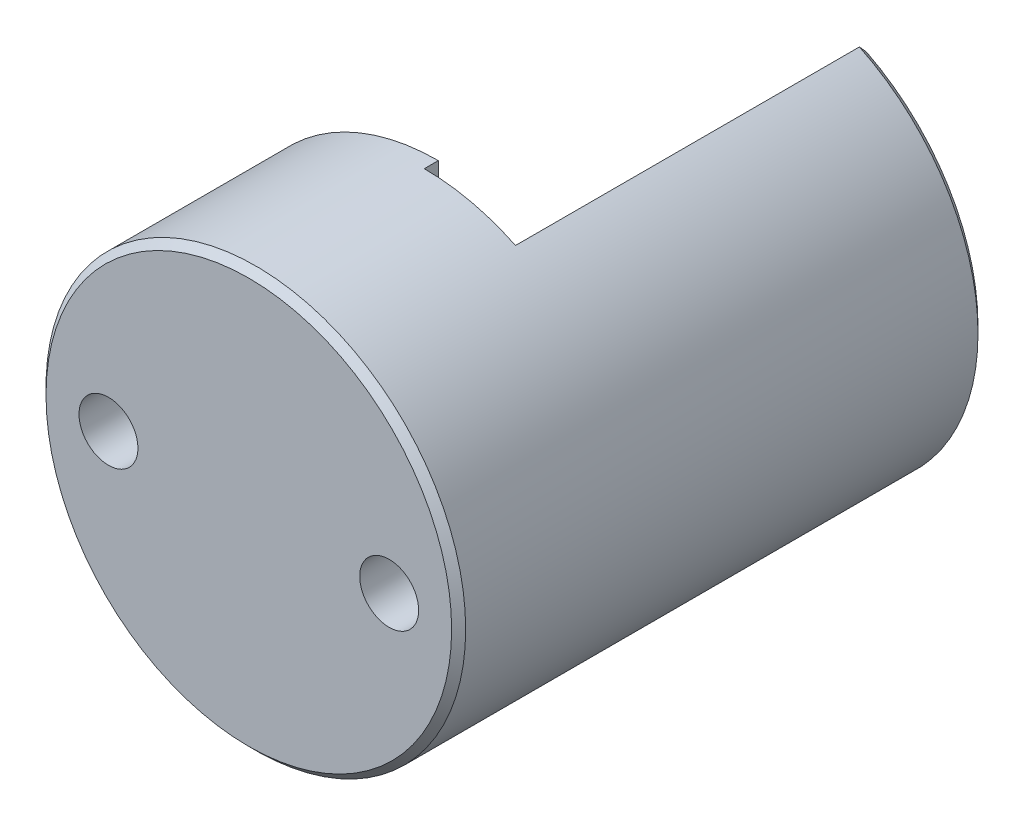
from build123d import *

# Parameters (mm, degrees)
SKETCH1_R           = 14.949572774
SKETCH1_R_2         = 2.099903903
BOSS_EXTRUDE1_DEPTH = 7.5
SKETCH2_R           = 14.949572774
BOSS_EXTRUDE2_DEPTH = 5
BOSS_EXTRUDE3_DEPTH = 1
BOSS_EXTRUDE4_DEPTH = 25
SKETCH5_R           = 2.099903903
CUT_EXTRUDE1_DEPTH  = 7
CHAMFER2_SIZE       = 0.5
CHAMFER3_SIZE       = 0.5


with BuildPart() as part:
    # Sketch1 → Boss-Extrude1 (new body)
    with BuildSketch(Plane.XY):
        Circle(SKETCH1_R)
        with Locations((9.999999776, -1e-09)):
            Circle(SKETCH1_R_2, mode=Mode.SUBTRACT)
        with Locations((-9.999999776, 1e-09)):
            Circle(SKETCH1_R_2, mode=Mode.SUBTRACT)
    extrude(amount=-BOSS_EXTRUDE1_DEPTH)

    # Sketch2 → Boss-Extrude2 (add)
    with BuildSketch(Plane(origin=(0, 0, -7.5), x_dir=(-1, 0, 0), z_dir=(0, 0, -1))):
        Circle(SKETCH2_R)
    extrude(amount=BOSS_EXTRUDE2_DEPTH)

    # Sketch3 → Boss-Extrude3 (add)
    with BuildSketch(Plane(origin=(0, 0, -12.5), x_dir=(-1, 0, 0), z_dir=(0, 0, -1))):
        with BuildLine():
            Line((-1e-09, 14.949572774), (-1e-09, -14.949572774))
            ThreePointArc((-1e-09, -14.949572774), (14.949572774, 0), (-1e-09, 14.949572774))
        make_face()
    extrude(amount=BOSS_EXTRUDE3_DEPTH)

    # Sketch4 → Boss-Extrude4 (add)
    with BuildSketch(Plane(origin=(0, 0, -12.5), x_dir=(-1, 0, 0), z_dir=(0, 0, -1))):
        with BuildLine():
            Line((-6.499816063, 13.462619257), (-6.499816063, -13.462619257))
            ThreePointArc((-6.499816063, -13.462619257), (-14.949572774, 0), (-6.499816063, 13.462619257))
        make_face()
    extrude(amount=BOSS_EXTRUDE4_DEPTH)

    # Sketch5 → Cut-Extrude1 (cut)
    with BuildSketch(Plane(origin=(0, 0, -37.5), x_dir=(-1, 0, 0), z_dir=(0, 0, -1))):
        with Locations((-9.999999776, -1e-09)):
            Circle(SKETCH5_R)
    extrude(amount=-CUT_EXTRUDE1_DEPTH, mode=Mode.SUBTRACT)

    # Chamfer2
    chamfer2_edges = [part.edges().sort_by_distance(p)[0] for p in [
        (14.949572774, 0, -37.5),
    ]]
    chamfer(chamfer2_edges, length=CHAMFER2_SIZE)

    # Chamfer3
    chamfer3_edges = [part.edges().sort_by_distance(p)[0] for p in [
        (-14.949572774, 0, 0),
    ]]
    chamfer(chamfer3_edges, length=CHAMFER3_SIZE)


solid = part.part
